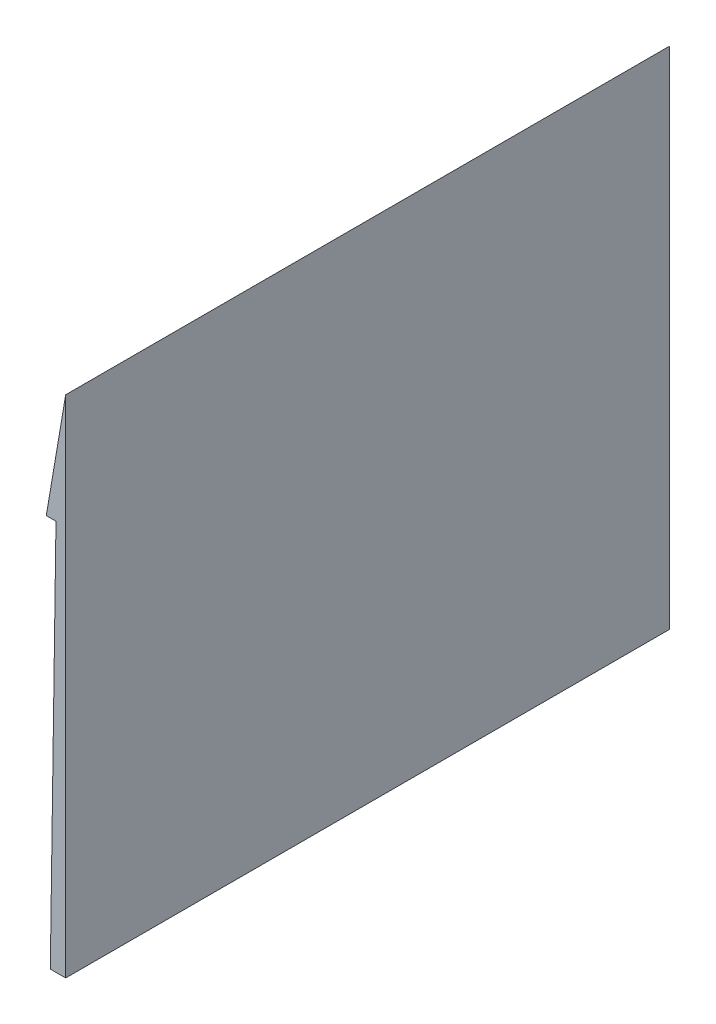
from build123d import *

# Parameters (mm, degrees)
BOSS_EXTRUDE1_DEPTH = 50


with BuildPart() as part:
    # Sketch1 → Boss-Extrude1 (new body, symmetric)
    with BuildSketch(Plane.XY):
        Polygon((0, 7.28867164), (0, 26.22867164), (-3.215197201, 7.28867164), (-1.6075986, 7.28867164), (-2.548367986, -57.396044964), (0, -57.396044964), align=None)
    extrude(amount=BOSS_EXTRUDE1_DEPTH, both=True)


solid = part.part
